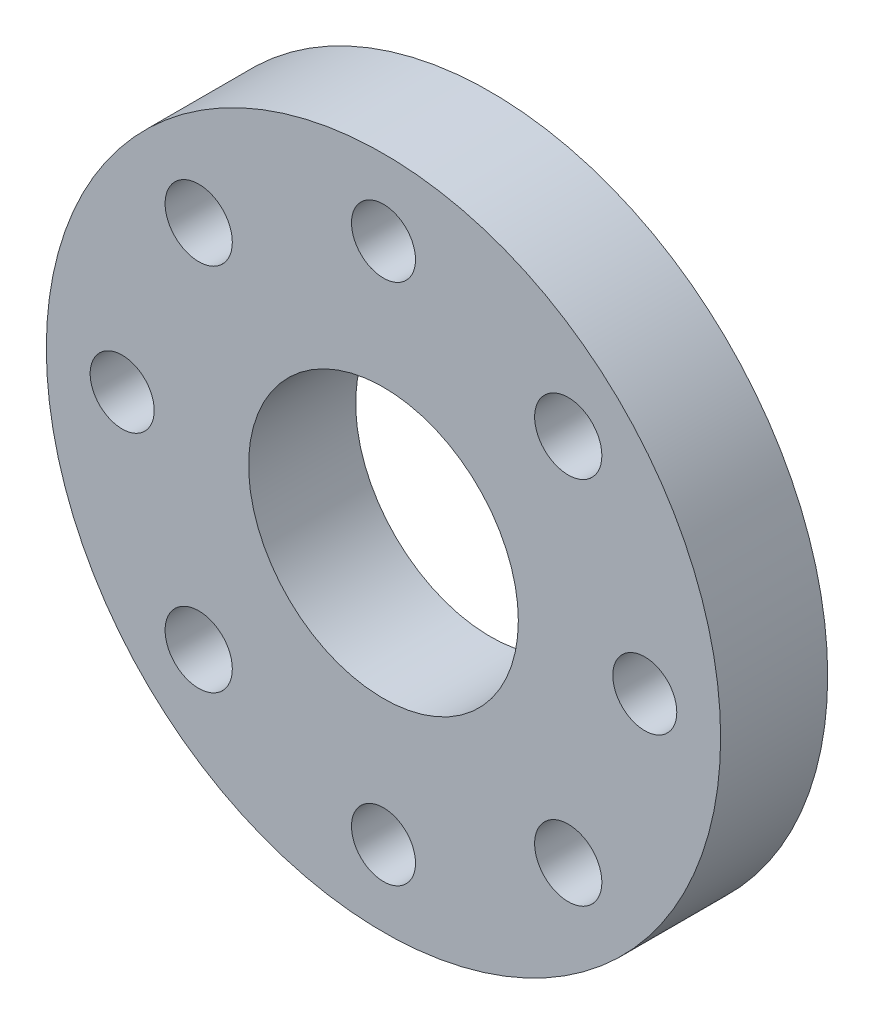
from build123d import *

# Parameters (mm, degrees)
SKETCH1_R           = 20
SKETCH1_R_2         = 8
SKETCH1_R_3         = 1.89865
SKETCH1_R_4         = 1.9939
BOSS_EXTRUDE1_DEPTH = 6.35


with BuildPart() as part:
    # Sketch1 → Boss-Extrude1 (new body)
    with BuildSketch(Plane.XY):
        Circle(SKETCH1_R)
        Circle(SKETCH1_R_2, mode=Mode.SUBTRACT)
        with Locations((0, -15.5)):
            Circle(SKETCH1_R_3, mode=Mode.SUBTRACT)
        with Locations((10.960155108, -10.960155108)):
            Circle(SKETCH1_R_4, mode=Mode.SUBTRACT)
        with Locations((-15.5, 0)):
            Circle(SKETCH1_R_3, mode=Mode.SUBTRACT)
        with Locations((-10.960155108, -10.960155108)):
            Circle(SKETCH1_R_4, mode=Mode.SUBTRACT)
        with Locations((0, 15.5)):
            Circle(SKETCH1_R_3, mode=Mode.SUBTRACT)
        with Locations((-10.960155108, 10.960155108)):
            Circle(SKETCH1_R_4, mode=Mode.SUBTRACT)
        with Locations((15.5, 0)):
            Circle(SKETCH1_R_3, mode=Mode.SUBTRACT)
        with Locations((10.960155108, 10.960155108)):
            Circle(SKETCH1_R_4, mode=Mode.SUBTRACT)
    extrude(amount=BOSS_EXTRUDE1_DEPTH)


solid = part.part
